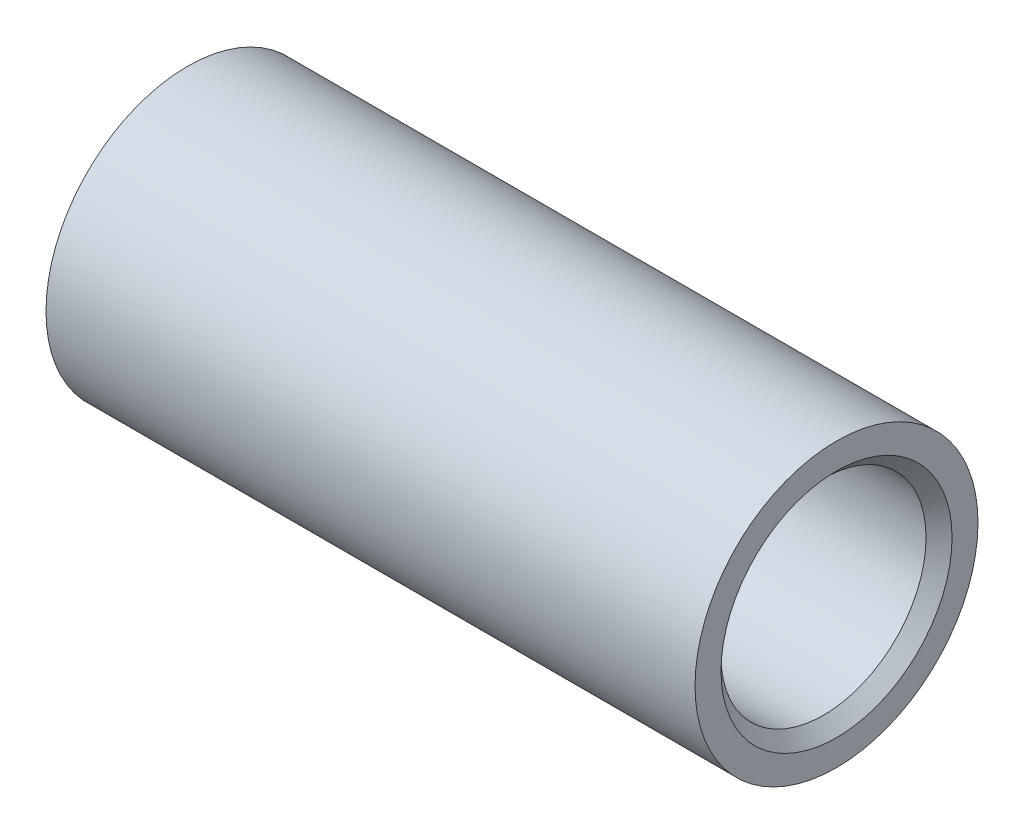
from build123d import *

# Parameters (mm, degrees)
CHAMFER1_SIZE = 0.254


with BuildPart() as part:
    # Sketch1 → Revolve1 (revolve)
    with BuildSketch(Plane.XY):
        with BuildLine():
            Line((0, 2.7686), (12.7, 2.7686))
            Line((12.7, 2.7686), (12.7, 2.0066))
            Line((12.7, 2.0066), (4.3434, 2.0066))
            ThreePointArc((4.3434, 2.0066), (4.81222687, 1.251446675), (4.992165092, 0.381))
            Line((4.992165092, 0.381), (4.484165092, 0.381))
            ThreePointArc((4.484165092, 0.381), (4.30422687, 1.251446675), (3.8354, 2.0066))
            Line((3.8354, 2.0066), (0, 2.0066))
            Line((0, 2.0066), (0, 2.7686))
        make_face()
    revolve(axis=Axis((-4.561757333, 0, 0), (1, 0, 0)))

    # Chamfer1
    chamfer1_edges = [part.edges().sort_by_distance(p)[0] for p in [
        (12.7, -2.0066, 0),
    ]]
    chamfer(chamfer1_edges, length=CHAMFER1_SIZE)


solid = part.part
